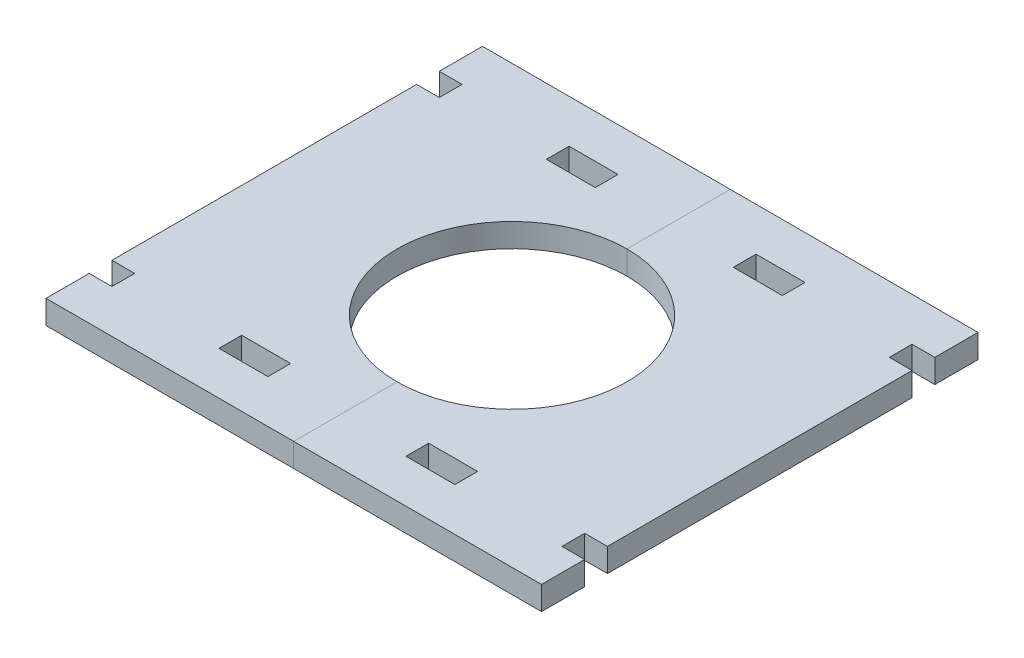
from build123d import *

# Parameters (mm, degrees)
SKETCH2_W               = 84
SKETCH2_H               = 74
SKETCH2_R               = 19.5
BOSS_EXTRUDE1_DEPTH     = 4
SKETCH4_W               = 8.3
SKETCH4_H               = 3.85
SKETCH4_W_2             = 3.85
CUT_EXTRUDE2_DEPTH      = 1
CUT_EXTRUDE2_DEPTH_BACK = 5


with BuildPart() as part:
    # Sketch2 → Boss-Extrude1 (new body)
    with BuildSketch(Plane(origin=(0, 0, 0), x_dir=(1, 0, 0), z_dir=(0, 1, 0))):
        Rectangle(SKETCH2_W, SKETCH2_H)
        Circle(SKETCH2_R, mode=Mode.SUBTRACT)
    extrude(amount=BOSS_EXTRUDE1_DEPTH)


with BuildPart() as body_2:
    # Split1: the piece on the far side of the plane
    add(part.part)
    split(bisect_by=Plane(origin=(0, 0, 0), x_dir=(0, 0, 1), z_dir=(1, 0, 0)), keep=Keep.BOTTOM)


with BuildPart() as part_1:
    add(part.part)

    # Split1
    split(bisect_by=Plane(origin=(0, 0, 0), x_dir=(0, 0, 1), z_dir=(1, 0, 0)), keep=Keep.TOP)


with BuildPart() as cut_extrude2_tool:
    # Sketch4 → Cut-Extrude2 (new body, two sides)
    with BuildSketch(Plane(origin=(0, 4, 0), x_dir=(1, 0, 0), z_dir=(0, 1, 0))) as cut_extrude2_sk:
        with Locations((-15.85, -27.75)):
            Rectangle(SKETCH4_W, SKETCH4_H)
        with Locations((-40.075, -27.75)):
            Rectangle(SKETCH4_W_2, SKETCH4_H)
        with Locations((40.075, -27.75)):
            Rectangle(SKETCH4_W_2, SKETCH4_H)
        with Locations((15.85, -27.75)):
            Rectangle(SKETCH4_W, SKETCH4_H)
        with Locations((15.85, 27.75)):
            Rectangle(SKETCH4_W, SKETCH4_H)
        with Locations((40.075, 27.75)):
            Rectangle(SKETCH4_W_2, SKETCH4_H)
        with Locations((-40.075, 27.75)):
            Rectangle(SKETCH4_W_2, SKETCH4_H)
        with Locations((-15.85, 27.75)):
            Rectangle(SKETCH4_W, SKETCH4_H)
    extrude(amount=CUT_EXTRUDE2_DEPTH)
    extrude(cut_extrude2_sk.sketch, amount=-CUT_EXTRUDE2_DEPTH_BACK)


with BuildPart() as part_2:
    add(part_1.part)

    # Cut-Extrude2: cut by cut_extrude2_tool
    add(cut_extrude2_tool.part, mode=Mode.SUBTRACT)


with BuildPart() as body_2_1:
    add(body_2.part)

    # Cut-Extrude2: cut by cut_extrude2_tool
    add(cut_extrude2_tool.part, mode=Mode.SUBTRACT)


solid = Compound([part_2.part, body_2_1.part])
